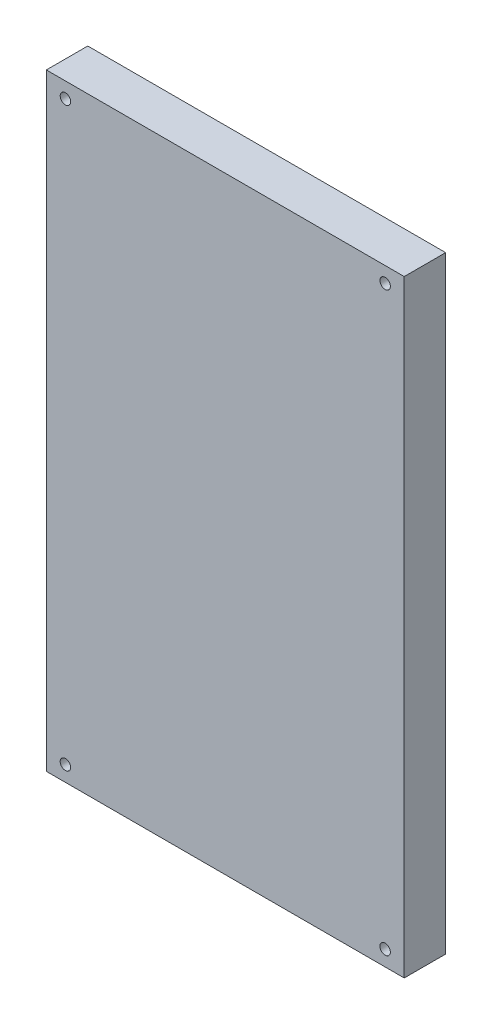
from build123d import *

# Parameters (mm, degrees)
SKETCH1_W           = 108.4
SKETCH1_H           = 184
SKETCH1_R           = 1.5875
BOSS_EXTRUDE1_DEPTH = 12.55


with BuildPart() as part:
    # Sketch1 → Boss-Extrude1 (new body)
    with BuildSketch(Plane.XY):
        with Locations((54.2, 92)):
            Rectangle(SKETCH1_W, SKETCH1_H)
        with Locations((5.78125, 4.6875)):
            Circle(SKETCH1_R, mode=Mode.SUBTRACT)
        with Locations((102.61875, 4.6875)):
            Circle(SKETCH1_R, mode=Mode.SUBTRACT)
        with Locations((5.78125, 179.3125)):
            Circle(SKETCH1_R, mode=Mode.SUBTRACT)
        with Locations((102.61875, 179.3125)):
            Circle(SKETCH1_R, mode=Mode.SUBTRACT)
    extrude(amount=BOSS_EXTRUDE1_DEPTH)


solid = part.part
